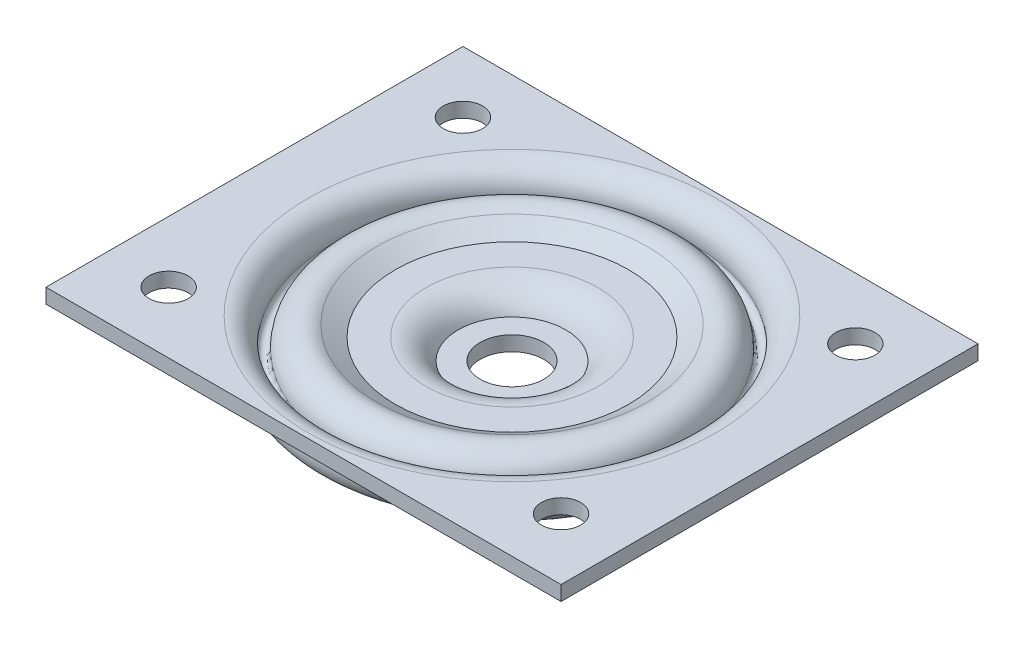
from build123d import *

# Parameters (mm, degrees)
SKETCH2_OUTSIDE_W   = 136.78
SKETCH2_OUTSIDE_H   = 136.78
SKETCH2_OUTSIDE_W_2 = 105
SKETCH2_OUTSIDE_H_2 = 85
CUT_EXTRUDE1_DEPTH  = 10
BOSS_EXTRUDE1_DEPTH = 3
SKETCH5_R           = 4
CUT_EXTRUDE2_DEPTH  = 12


with BuildPart() as part:
    # Sketch1 → Revolve1 (revolve)
    with BuildSketch(Plane.XY):
        with BuildLine():
            Line((6.5, 3), (6.5, 0))
            Line((6.5, 0), (13.3, 0))
            ThreePointArc((13.3, 0), (14.530151519, 2.969848481), (17.5, 4.2))
            Line((17.5, 4.2), (24.6, 4.2))
            Line((24.6, 4.2), (29.075562513, 6.847515853))
            ThreePointArc((29.075562513, 6.847515853), (30.939698005, 6.838522427), (31.81365802, 5.191927181))
            ThreePointArc((31.81365802, 5.191927181), (36.120367216, 1), (39.722916893, 5.810575165))
            ThreePointArc((39.722916893, 5.810575165), (40.090070438, 7.328480837), (41.5, 8))
            Line((41.5, 8), (52.5, 8))
            Line((52.5, 8), (52.5, 11))
            Line((52.5, 11), (41.5, 11))
            ThreePointArc((41.5, 11), (37.760778719, 9.219089228), (36.78706458, 5.193508558))
            ThreePointArc((36.78706458, 5.193508558), (35.886427161, 3.990864766), (34.809749862, 5.038846562))
            ThreePointArc((34.809749862, 5.038846562), (32.491953303, 9.405720022), (27.548149521, 9.429571149))
            Line((27.548149521, 9.429571149), (23.779112579, 7.2))
            Line((23.779112579, 7.2), (17.5, 7.2))
            ThreePointArc((17.5, 7.2), (13.611555581, 6.059702963), (10.954772731, 3))
            Line((10.954772731, 3), (6.5, 3))
        make_face()
    revolve(axis=Axis((0, 0, 0), (0, 1, 0)))

    # Sketch2 outside → Cut-Extrude1 (cut)
    with BuildSketch(Plane(origin=(0, 11, 0), x_dir=(1, 0, 0), z_dir=(0, 1, 0))):
        Rectangle(SKETCH2_OUTSIDE_W, SKETCH2_OUTSIDE_H)
        Rectangle(SKETCH2_OUTSIDE_W_2, SKETCH2_OUTSIDE_H_2, mode=Mode.SUBTRACT)
    extrude(amount=-CUT_EXTRUDE1_DEPTH, mode=Mode.SUBTRACT)

    # Sketch4 → Boss-Extrude1 (add)
    with BuildSketch(Plane(origin=(0, 11, 0), x_dir=(1, 0, 0), z_dir=(0, 1, 0))):
        with BuildLine():
            ThreePointArc((-52.5, 8.38e-07), (-46.767556277, 23.854678365), (-30.822070015, 42.5))
            Line((-30.822070015, 42.5), (-52.500000043, 42.5))
            Line((-52.500000043, 42.5), (-52.500000043, 8.38e-07))
        make_face()
        with BuildLine():
            ThreePointArc((-30.822070015, -42.5), (-46.767556657, -23.854677619), (-52.5, 8.38e-07))
            Line((-52.500000043, 8.38e-07), (-52.500000043, -42.5))
            Line((-52.500000043, -42.5), (-30.822070015, -42.5))
        make_face()
        with BuildLine():
            Line((52.5, 42.5), (30.822070015, 42.5))
            ThreePointArc((30.822070015, 42.5), (46.767556467, 23.854677992), (52.5, 0))
            Line((52.5, 0), (52.5, 42.5))
        make_face()
        with BuildLine():
            Line((52.5, -42.5), (52.5, 0))
            ThreePointArc((52.5, 0), (46.767556467, -23.854677992), (30.822070015, -42.5))
            Line((30.822070015, -42.5), (52.5, -42.5))
        make_face()
    extrude(amount=-BOSS_EXTRUDE1_DEPTH)

    # Sketch5 → Cut-Extrude2 (cut, through all)
    with BuildSketch(Plane(origin=(0, 11, 0), x_dir=(1, 0, 0), z_dir=(0, 1, 0))):
        with Locations((-40, 30)):
            Circle(SKETCH5_R)
        with Locations((40, 30)):
            Circle(SKETCH5_R)
        with Locations((40, -30)):
            Circle(SKETCH5_R)
        with Locations((-40, -30)):
            Circle(SKETCH5_R)
    extrude(amount=-CUT_EXTRUDE2_DEPTH, mode=Mode.SUBTRACT)


solid = part.part
